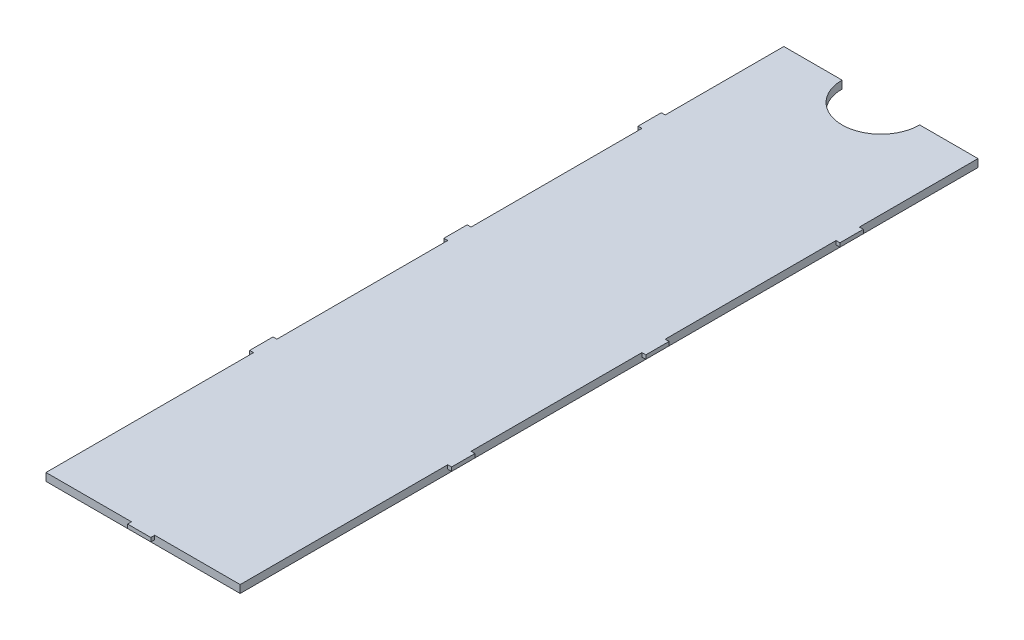
from build123d import *

# Parameters (mm, degrees)
SKETCH1_W           = 25
SKETCH1_H           = 95
BOSS_EXTRUDE1_DEPTH = 1
BOSS_EXTRUDE2_START = -0.5
SKETCH3_W           = 3
SKETCH3_H           = 1
SKETCH3_W_2         = 1
SKETCH3_H_2         = 3
BOSS_EXTRUDE2_DEPTH = 0.5
SKETCH4_R           = 5
CUT_EXTRUDE1_DEPTH  = 1


with BuildPart() as part:
    # Sketch1 → Boss-Extrude1 (new body)
    with BuildSketch(Plane.XZ.offset(-34.2740501)):
        with Locations((-81.601257217, 49.307503177)):
            Rectangle(SKETCH1_W, SKETCH1_H)
    extrude(amount=-BOSS_EXTRUDE1_DEPTH)

    # Sketch3 → Boss-Extrude2 (add)
    with BuildSketch(Plane.XZ.offset(-34.2740501).offset(BOSS_EXTRUDE2_START)):
        with Locations((-81.601257217, 96.807503177)):
            Rectangle(SKETCH3_W, SKETCH3_H)
        with Locations((-94.101257217, 68.580262086)):
            Rectangle(SKETCH3_W_2, SKETCH3_H_2)
        with Locations((-94.101257217, 43.580262086)):
            Rectangle(SKETCH3_W_2, SKETCH3_H_2)
        with Locations((-94.101257217, 18.580262086)):
            Rectangle(SKETCH3_W_2, SKETCH3_H_2)
        with Locations((-69.101257217, 18.580262086)):
            Rectangle(SKETCH3_W_2, SKETCH3_H_2)
        with Locations((-69.101257217, 43.580262086)):
            Rectangle(SKETCH3_W_2, SKETCH3_H_2)
        with Locations((-69.101257217, 68.580262086)):
            Rectangle(SKETCH3_W_2, SKETCH3_H_2)
    extrude(amount=-BOSS_EXTRUDE2_DEPTH)

    # Sketch4 → Cut-Extrude1 (cut)
    with BuildSketch(Plane.XZ.offset(-34.2740501)):
        with Locations((-81.601257217, 1.807503177)):
            Circle(SKETCH4_R)
    extrude(amount=-CUT_EXTRUDE1_DEPTH, mode=Mode.SUBTRACT)


solid = part.part
